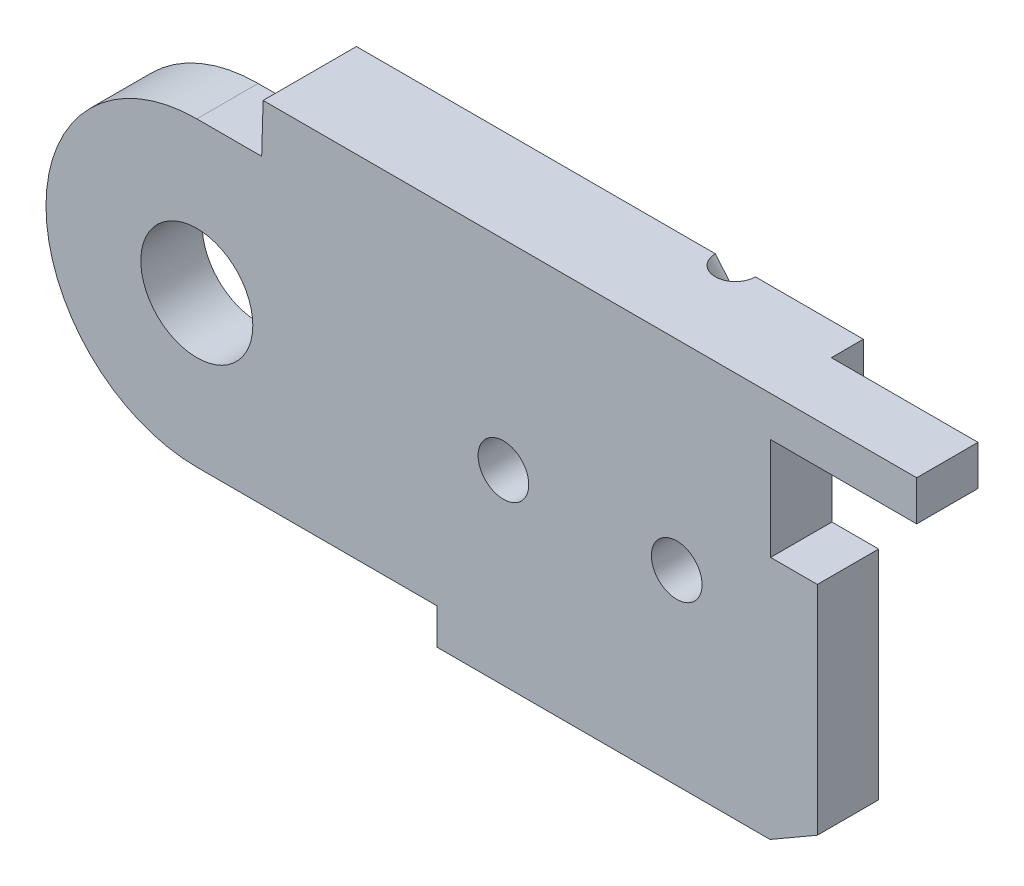
from build123d import *

# Parameters (mm, degrees)
BOSS_EXTRUDE1_DEPTH  = 2
BOSS_EXTRUDE6_DEPTH  = 2.5
CUT_EXTRUDE6_DEPTH   = 2.5
BOSS_EXTRUDE14_DEPTH = 2.3
SKETCH32_R           = 2.1
CUT_EXTRUDE7_DEPTH   = 2.3
SKETCH33_W           = 12.5
SKETCH33_H           = 1.343145751
BOSS_EXTRUDE15_DEPTH = 1.2
SKETCH35_W           = 5.479645997
SKETCH35_H           = 3.827993755
CUT_EXTRUDE8_DEPTH   = 2.4
SKETCH36_W           = 3.7
SKETCH36_H           = 1.827993755
CUT_EXTRUDE9_DEPTH   = 2.4
SKETCH37_R           = 3.9
BOSS_EXTRUDE16_DEPTH = 2.3
CUT_EXTRUDE10_DEPTH  = 5.3
SKETCH43_R           = 2.5
BOSS_EXTRUDE17_DEPTH = 1.2
SKETCH44_R           = 0.95
CUT_EXTRUDE11_DEPTH  = 9
SKETCH45_R           = 2
CUT_EXTRUDE12_DEPTH  = 2.5
SKETCH52_R           = 0.75
CUT_EXTRUDE13_DEPTH  = 10


with BuildPart() as part:
    # Sketch3 → Boss-Extrude1 (new body)
    with BuildSketch(Plane.XY):
        with BuildLine():
            Line((8, 0), (9, -2.5))
            Line((9, -2.5), (9, -7))
            Line((9, -7), (21.5, -7))
            Line((21.5, -7), (25.050252532, -4.949747468))
            ThreePointArc((25.050252532, -4.949747468), (36.467156728, -2.678784027), (30, 7))
            Line((30, 7), (27, 7.5))
            Line((27, 7.5), (5.656854249, 7.5))
            Line((5.656854249, 7.5), (5.656854249, 5.656854249))
            ThreePointArc((5.656854249, 5.656854249), (7.39103626, 3.061467459), (8, 0))
        make_face()
    extrude(amount=BOSS_EXTRUDE1_DEPTH)

    # Sketch22 → Boss-Extrude6 (add)
    with BuildSketch(Plane.XY.offset(2)):
        with BuildLine():
            Line((5.656854249, 5.656854249), (2.486790148, 5.656854249))
            Line((2.486790148, 5.656854249), (2.486790148, 7.5))
            Line((2.486790148, 7.5), (5.656854249, 7.5))
            Line((5.656854249, 7.5), (21.5, 7.5))
            Line((21.5, 7.5), (27, 7.5))
            Line((27, 7.5), (27, 2.172006245))
            Line((27, 2.172006245), (23.275126266, 2.172006245))
            Line((23.275126266, 2.172006245), (23.275126266, -5.974873734))
            Line((23.275126266, -5.974873734), (21.5, -7))
            Line((21.5, -7), (9, -7))
            Line((9, -7), (9, -2.5))
            Line((9, -2.5), (8, 0))
            ThreePointArc((8, 0), (7.39103626, 3.061467459), (5.656854249, 5.656854249))
        make_face()
    extrude(amount=BOSS_EXTRUDE6_DEPTH)

    # Sketch26 → Cut-Extrude6 (cut)
    with BuildSketch(Plane.XY.offset(2)):
        Polygon((18.098080448, 5.3), (2.530052458, 5.3), (2.530052458, 4), (18.098080448, 4), (27, 4), (27, 5.3), align=None)
    extrude(amount=CUT_EXTRUDE6_DEPTH, mode=Mode.SUBTRACT)


with BuildPart() as body_2:
    # Sketch31 → Boss-Extrude14 (new body)
    with BuildSketch(Plane.XY.offset(4.5)):
        with BuildLine():
            Line((2.432688066, 5.656854249), (0, 5.656854249))
            ThreePointArc((0, 5.656854249), (-5.656854249, 0), (0, -5.656854249))
            Line((0, -5.656854249), (9, -5.656854249))
            Line((9, -5.656854249), (9, -7))
            Line((9, -7), (21.5, -7))
            Line((21.5, -7), (23.275126266, -5.974873734))
            Line((23.275126266, -5.974873734), (23.275126266, 2.172006245))
            Line((23.275126266, 2.172006245), (27, 2.172006245))
            Line((27, 2.172006245), (27, 7.5))
            Line((27, 7.5), (2.486790148, 7.5))
            Line((2.486790148, 7.5), (2.432688066, 5.656854249))
        make_face()
    extrude(amount=BOSS_EXTRUDE14_DEPTH)

    # Sketch32 → Cut-Extrude7 (cut)
    with BuildSketch(Plane.XY.offset(6.8)):
        Circle(SKETCH32_R)
    extrude(amount=-CUT_EXTRUDE7_DEPTH, mode=Mode.SUBTRACT)

    # Sketch33 → Boss-Extrude15 (add)
    with BuildSketch(Plane.XY.offset(6.8)):
        with Locations((15.25, -6.328427125)):
            Rectangle(SKETCH33_W, SKETCH33_H)
        Polygon((2.486790148, 7.5), (21.5, 7.5), (21.5, 5.656854249), (2.432688066, 5.656854249), align=None)
    extrude(amount=BOSS_EXTRUDE15_DEPTH)


with BuildPart() as cut_extrude8_tool:
    # Sketch35 → Cut-Extrude8 (new body)
    with BuildSketch(Plane.XY.offset(6.8)):
        with Locations((24.260177002, 4.086003123)):
            Rectangle(SKETCH35_W, SKETCH35_H)
    extrude(amount=-CUT_EXTRUDE8_DEPTH)


with BuildPart() as part_1:
    add(part.part)

    # Cut-Extrude8: cut by cut_extrude8_tool
    add(cut_extrude8_tool.part, mode=Mode.SUBTRACT)

    # Sketch36 → Cut-Extrude9 (cut)
    with BuildSketch(Plane.XY.offset(4.4)):
        with Locations((25.15, 3.086003123)):
            Rectangle(SKETCH36_W, SKETCH36_H)
    extrude(amount=-CUT_EXTRUDE9_DEPTH, mode=Mode.SUBTRACT)

    # Sketch37 → Boss-Extrude16 (add)
    with BuildSketch(Plane.XY.offset(2)):
        with Locations((30, 0)):
            Circle(SKETCH37_R)
    extrude(amount=BOSS_EXTRUDE16_DEPTH)

    # Sketch39 → Cut-Extrude10 (cut, through all)
    with BuildSketch(Plane.XY.offset(4.3)):
        with BuildLine():
            Line((29, 1.732050808), (29, -1.732050808))
            ThreePointArc((29, -1.732050808), (32, 0), (29, 1.732050808))
        make_face()
    extrude(amount=-CUT_EXTRUDE10_DEPTH, mode=Mode.SUBTRACT)


with BuildPart() as body_2_1:
    add(body_2.part)

    # Cut-Extrude8: cut by cut_extrude8_tool
    add(cut_extrude8_tool.part, mode=Mode.SUBTRACT)

    # Sketch43 → Boss-Extrude17 (add)
    with BuildSketch(Plane.XY.offset(6.8)):
        with Locations((11.5, 0)):
            Circle(SKETCH43_R)
        with Locations((18, 0)):
            Circle(SKETCH43_R)
    extrude(amount=BOSS_EXTRUDE17_DEPTH)


with BuildPart() as cut_extrude11_tool:
    # Sketch44 → Cut-Extrude11 (new body, through all)
    with BuildSketch(Plane.XY.offset(8)):
        with Locations((11.5, 0)):
            Circle(SKETCH44_R)
        with Locations((18, 0)):
            Circle(SKETCH44_R)
    extrude(amount=-CUT_EXTRUDE11_DEPTH)


with BuildPart() as part_2:
    add(part_1.part)

    # Cut-Extrude11: cut by cut_extrude11_tool
    add(cut_extrude11_tool.part, mode=Mode.SUBTRACT)

    # Sketch45 → Cut-Extrude12 (cut)
    with BuildSketch(Plane(origin=(0, 0, 0), x_dir=(-1, 0, 0), z_dir=(0, 0, -1))):
        with Locations((-11.5, 0)):
            Circle(SKETCH45_R)
        with Locations((-18, 0)):
            Circle(SKETCH45_R)
    extrude(amount=-CUT_EXTRUDE12_DEPTH, mode=Mode.SUBTRACT)


with BuildPart() as body_2_2:
    add(body_2_1.part)

    # Cut-Extrude11: cut by cut_extrude11_tool
    add(cut_extrude11_tool.part, mode=Mode.SUBTRACT)

    # Sketch52 → Cut-Extrude13 (cut, along a direction that is not the sketch's normal)
    with BuildSketch(Plane.XZ.offset(-5.656854249)):
        with Locations((18.235476819, 8)):
            Circle(SKETCH52_R)
    extrude(amount=-CUT_EXTRUDE13_DEPTH, dir=(0.640410196, -0.76803306, 0), mode=Mode.SUBTRACT)


with BuildPart() as body_3:
    # Mirror1: mirrored copy
    add(body_2_2.part.mirror(Plane.XY.offset(8)))


with BuildPart() as body_4:
    # Mirror1 2: mirrored copy
    add(part_2.part.mirror(Plane.XY.offset(8)))


solid = body_3.part
